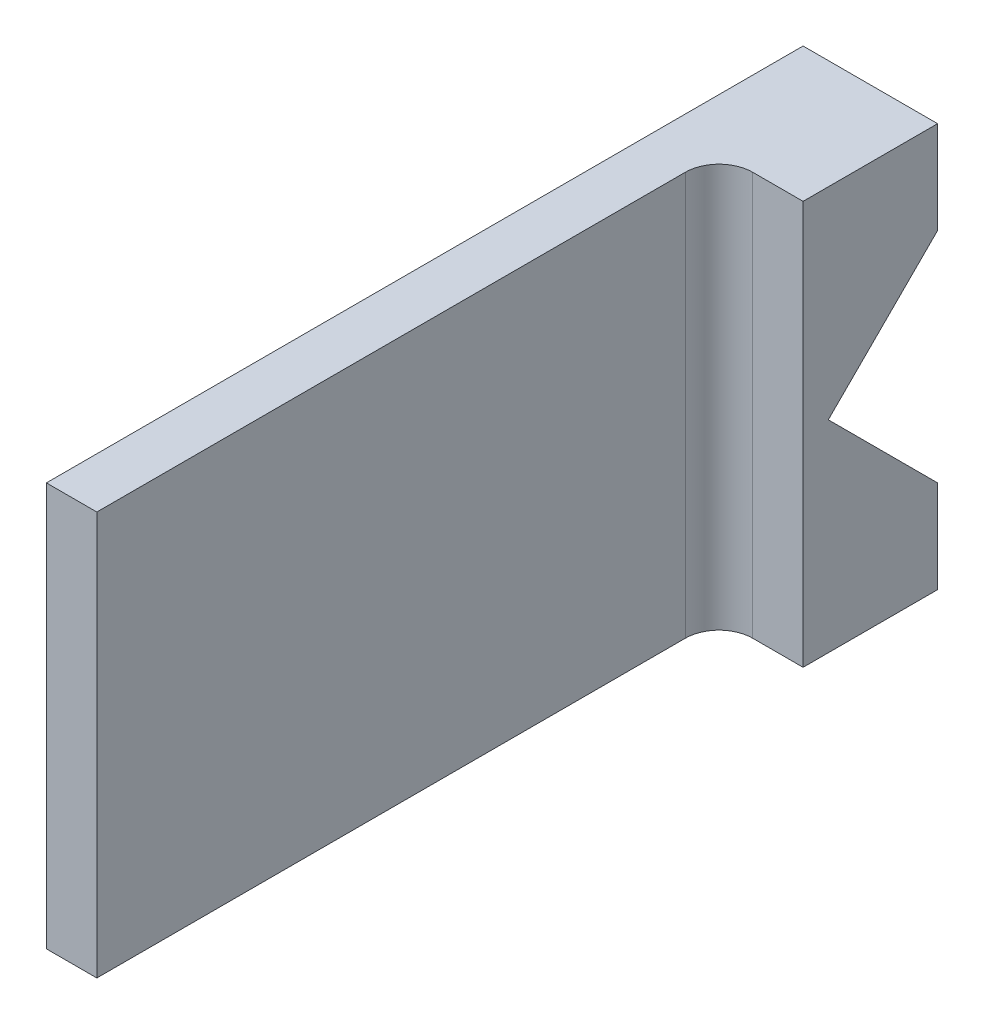
from build123d import *

# Parameters (mm, degrees)
BOSS_EXTRUDE1_DEPTH = 12.7
SKETCH2_W           = 7.9375
SKETCH2_H           = 58.7375
CUT_EXTRUDE1_DEPTH  = 39.1
FILLET1_R           = 3.175


with BuildPart() as part:
    # Sketch1 → Boss-Extrude1 (new body)
    with BuildSketch(Plane(origin=(0, 0, 0), x_dir=(0, 0, -1), z_dir=(1, 0, 0))):
        Polygon((0, -10.31875), (0, -19.05), (-71.4375, -19.05), (-71.4375, 19.05), (0, 19.05), (0, 10.31875), (-10.31875, 0), align=None)
    extrude(amount=BOSS_EXTRUDE1_DEPTH)

    # Sketch2 → Cut-Extrude1 (cut, through all)
    with BuildSketch(Plane(origin=(0, 19.05, 0), x_dir=(1, 0, 0), z_dir=(0, 1, 0))):
        with Locations((8.73125, -42.06875)):
            Rectangle(SKETCH2_W, SKETCH2_H)
    extrude(amount=-CUT_EXTRUDE1_DEPTH, mode=Mode.SUBTRACT)

    # Fillet1
    fillet1_edges = [part.edges().sort_by_distance(p)[0] for p in [
        (4.7625, 0, 12.7),
    ]]
    fillet(fillet1_edges, radius=FILLET1_R)


solid = part.part
